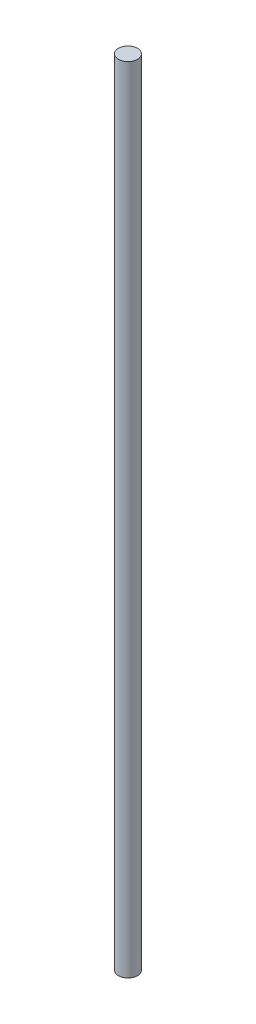
from build123d import *

# Parameters (mm, degrees)
CROQUIS1_R              = 4
SALIENTE_EXTRUIR1_DEPTH = 332.21


with BuildPart() as part:
    # Croquis1 → Saliente-Extruir1 (new body)
    with BuildSketch(Plane(origin=(0, 0, 0), x_dir=(1, 0, 0), z_dir=(0, 1, 0))):
        Circle(CROQUIS1_R)
    extrude(amount=SALIENTE_EXTRUIR1_DEPTH)


solid = part.part
